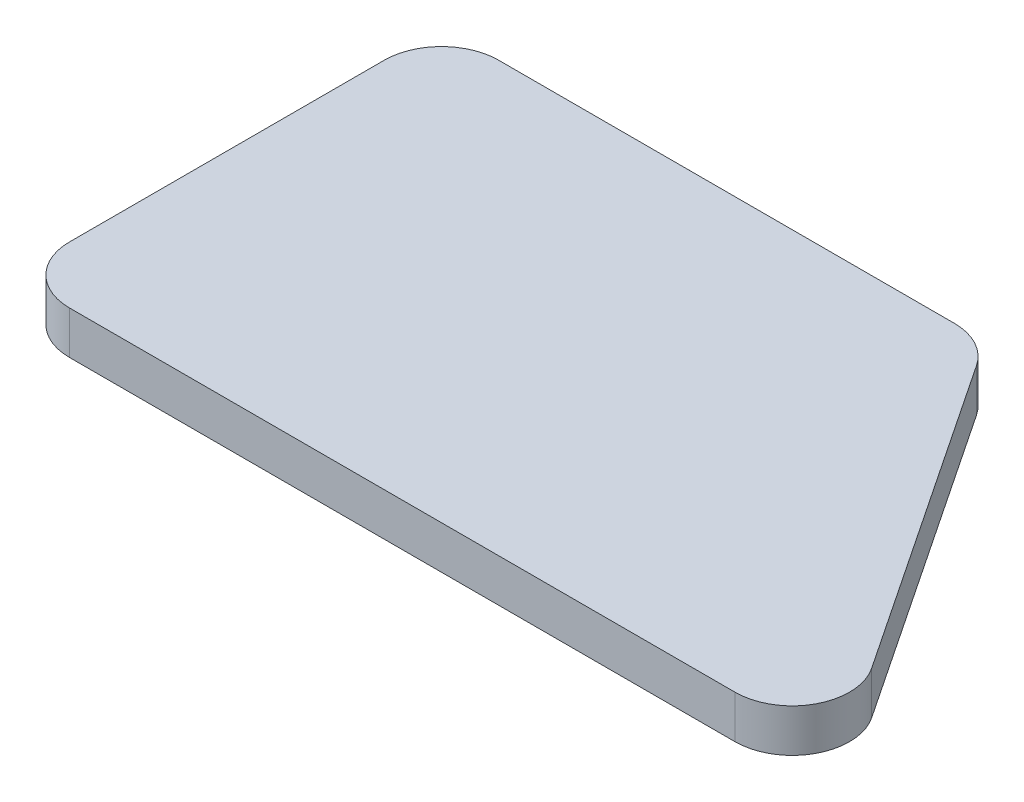
from build123d import *

# Parameters (mm, degrees)
EXTRUDE_1_DEPTH = 1.5


with BuildPart() as part:
    # 草图1 → 凸台-拉伸1 (new body)
    with BuildSketch(Plane(origin=(0, 0, 0), x_dir=(1, 0, 0), z_dir=(0, 1, 0))):
        with BuildLine():
            Line((-1.070367517, 0), (-17, 0))
            ThreePointArc((-17, 0), (-18.414213562, -0.585786438), (-19, -2))
            Line((-19, -2), (-19, -13))
            ThreePointArc((-19, -13), (-18.414213562, -14.414213562), (-17, -15))
            Line((-17, -15), (6.262965816, -15))
            ThreePointArc((6.262965816, -15), (8.026315014, -13.943715851), (7.927066405, -11.890599608))
            Line((7.927066405, -11.890599608), (0.593733072, -0.890599608))
            ThreePointArc((0.593733072, -0.890599608), (-0.126651666, -0.236650802), (-1.070367517, 0))
        make_face()
    extrude(amount=EXTRUDE_1_DEPTH)


solid = part.part
